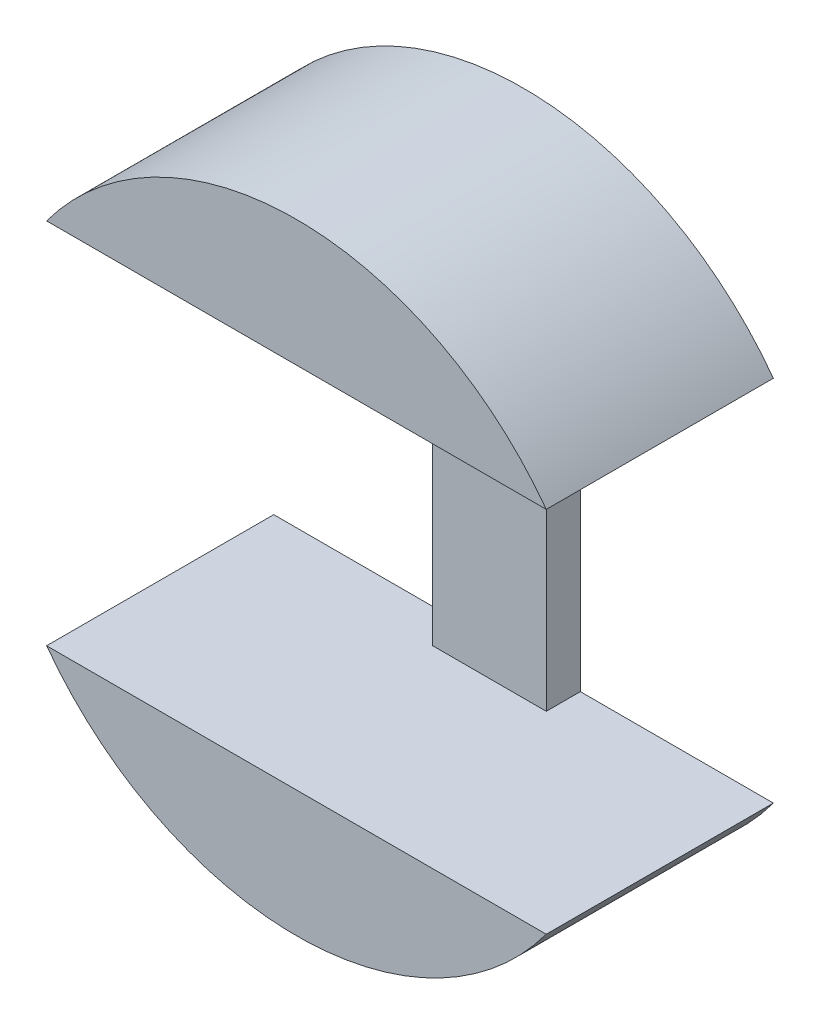
from build123d import *

# Parameters (mm, degrees)
EXTRUDE_1_DEPTH     = 10
SKETCH_3_W          = 5
SKETCH_3_H          = 16.2
CUT_EXTRUDE_1_DEPTH = 8.5


with BuildPart() as part:
    # Эскиз2 → Бобышка-Вытянуть1 (new body)
    with BuildSketch(Plane.XY):
        with BuildLine():
            Line((-2.5, 8.1), (-11, 8.1))
            ThreePointArc((-11, 8.1), (0, 13.660527076), (11, 8.1))
            Line((11, 8.1), (2.5, 8.1))
            Line((2.5, 8.1), (2.5, -8.1))
            Line((2.5, -8.1), (11, -8.1))
            ThreePointArc((11, -8.1), (0, -13.660527076), (-11, -8.1))
            Line((-11, -8.1), (-2.5, -8.1))
            Line((-2.5, -8.1), (-2.5, 8.1))
        make_face()
    extrude(amount=EXTRUDE_1_DEPTH)

    # Эскиз3 → Вырез-Вытянуть1 (cut)
    with BuildSketch(Plane.XY.offset(10)):
        Rectangle(SKETCH_3_W, SKETCH_3_H)
    extrude(amount=-CUT_EXTRUDE_1_DEPTH, mode=Mode.SUBTRACT)


solid = part.part
